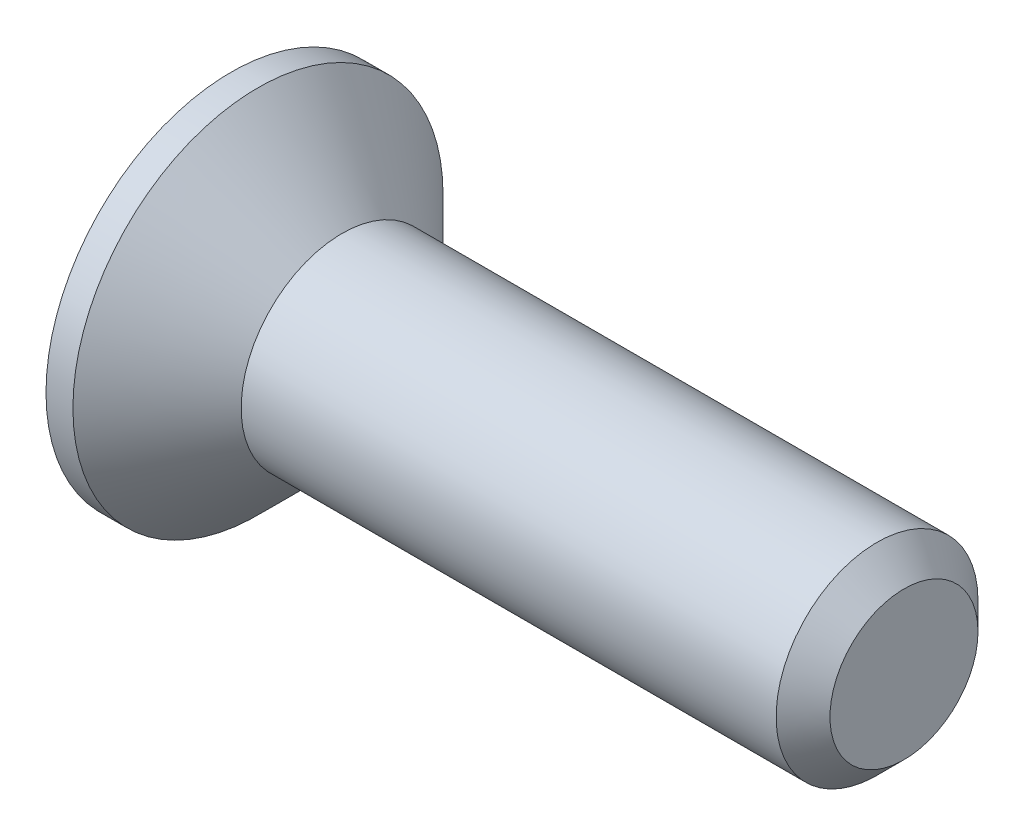
from build123d import *

# Parameters (mm, degrees)
CUT_EXTRUDE1_DEPTH = 0.83
CHAMFER2_SIZE      = 0.05


with BuildPart() as part:
    # Sketch1 → Revolve1 (revolve)
    with BuildSketch(Plane.XY):
        Polygon((-4.212732686, 1.5), (-5.462732686, 2.75), (-5.862732686, 2.75), (-5.862732686, 0), (4.137267314, 0), (4.137267314, 1.1), (3.737267314, 1.5), align=None)
    revolve(axis=Axis((48.184792793, 0, 0), (-1, 0, 0)))

    # Sketch2 → Cut-Extrude1 (cut)
    with BuildSketch(Plane.ZY.offset(5.862732686)):
        with BuildLine():
            ThreePointArc((1.16663108, 0.344585397), (1.212435565, 0.7), (0.881735248, 0.838039454))
            ThreePointArc((0.881735248, 0.838039454), (0.5125, 0.887676039), (0.284895833, 1.182624851))
            ThreePointArc((0.284895833, 1.182624851), (0, 1.4), (-0.284895833, 1.182624851))
            ThreePointArc((-0.284895833, 1.182624851), (-0.5125, 0.887676039), (-0.881735248, 0.838039454))
            ThreePointArc((-0.881735248, 0.838039454), (-1.212435565, 0.7), (-1.16663108, 0.344585397))
            ThreePointArc((-1.16663108, 0.344585397), (-1.025, 0), (-1.16663108, -0.344585397))
            ThreePointArc((-1.16663108, -0.344585397), (-1.212435565, -0.7), (-0.881735248, -0.838039454))
            ThreePointArc((-0.881735248, -0.838039454), (-0.5125, -0.887676039), (-0.284895833, -1.182624851))
            ThreePointArc((-0.284895833, -1.182624851), (0, -1.4), (0.284895833, -1.182624851))
            ThreePointArc((0.284895833, -1.182624851), (0.5125, -0.887676039), (0.881735248, -0.838039454))
            ThreePointArc((0.881735248, -0.838039454), (1.212435565, -0.7), (1.16663108, -0.344585397))
            ThreePointArc((1.16663108, -0.344585397), (1.025, 0), (1.16663108, 0.344585397))
        make_face()
    extrude(amount=-CUT_EXTRUDE1_DEPTH, mode=Mode.SUBTRACT)

    # Chamfer2
    chamfer2_edges = [part.edges().sort_by_distance(p)[0] for p in [
        (-5.862732686, 0.887676039, 0.5125),
        (-5.862732686, 0, 1.025),
        (-5.862732686, -0.887676039, 0.5125),
        (-5.862732686, -0.887676039, -0.5125),
        (-5.862732686, 0, -1.025),
        (-5.862732686, 0.887676039, -0.5125),
        (-5.862732686, 1.4, 0),
        (-5.862732686, 0.7, -1.212435565),
        (-5.862732686, -0.7, -1.212435565),
        (-5.862732686, -1.4, 0),
        (-5.862732686, -0.7, 1.212435565),
        (-5.862732686, 0.7, 1.212435565),
    ]]
    chamfer(chamfer2_edges, length=CHAMFER2_SIZE)


solid = part.part
